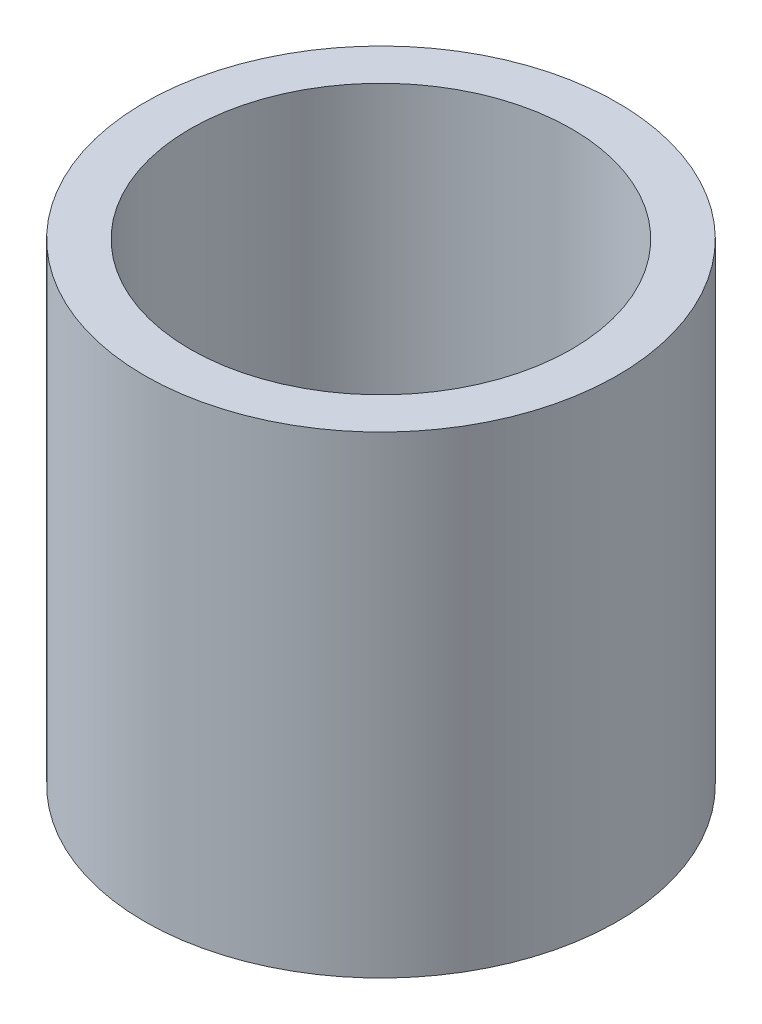
from build123d import *

# Parameters (mm, degrees)
SKETCH_1_W = 4.9
SKETCH_1_H = 50.8


with BuildPart() as part:
    # 草图1 → 旋转1 (revolve)
    with BuildSketch(Plane.XY, mode=Mode.PRIVATE) as revolve_1_sk:
        with Locations((22.95, 25.4)):
            Rectangle(SKETCH_1_W, SKETCH_1_H)
    revolve(revolve_1_sk.sketch.rotate(Axis((0, 161.376166943, 0), (0, -1, 0)), 90), axis=Axis((0, 161.376166943, 0), (0, -1, 0)))  # turned: the seam where the file's is


solid = part.part
